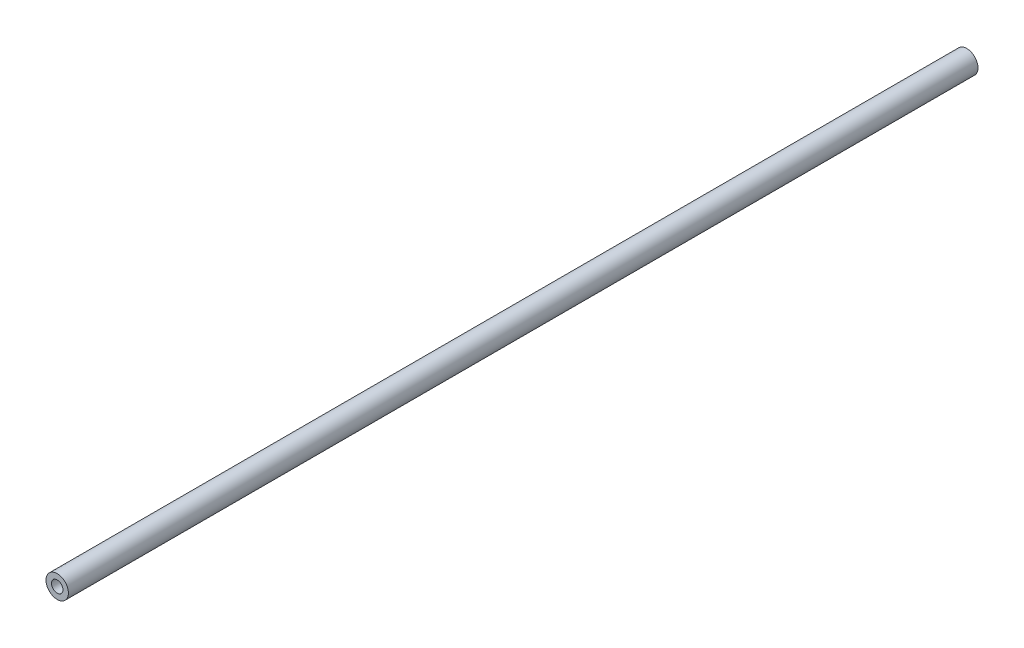
from build123d import *

# Parameters (mm, degrees)
CROQUIS1_R              = 1.85
CROQUIS1_R_2            = 0.95
SALIENTE_EXTRUIR1_DEPTH = 150


with BuildPart() as part:
    # Croquis1 → Saliente-Extruir1 (new body)
    with BuildSketch(Plane.XY):
        Circle(CROQUIS1_R)
        Circle(CROQUIS1_R_2, mode=Mode.SUBTRACT)
    extrude(amount=SALIENTE_EXTRUIR1_DEPTH)


solid = part.part
